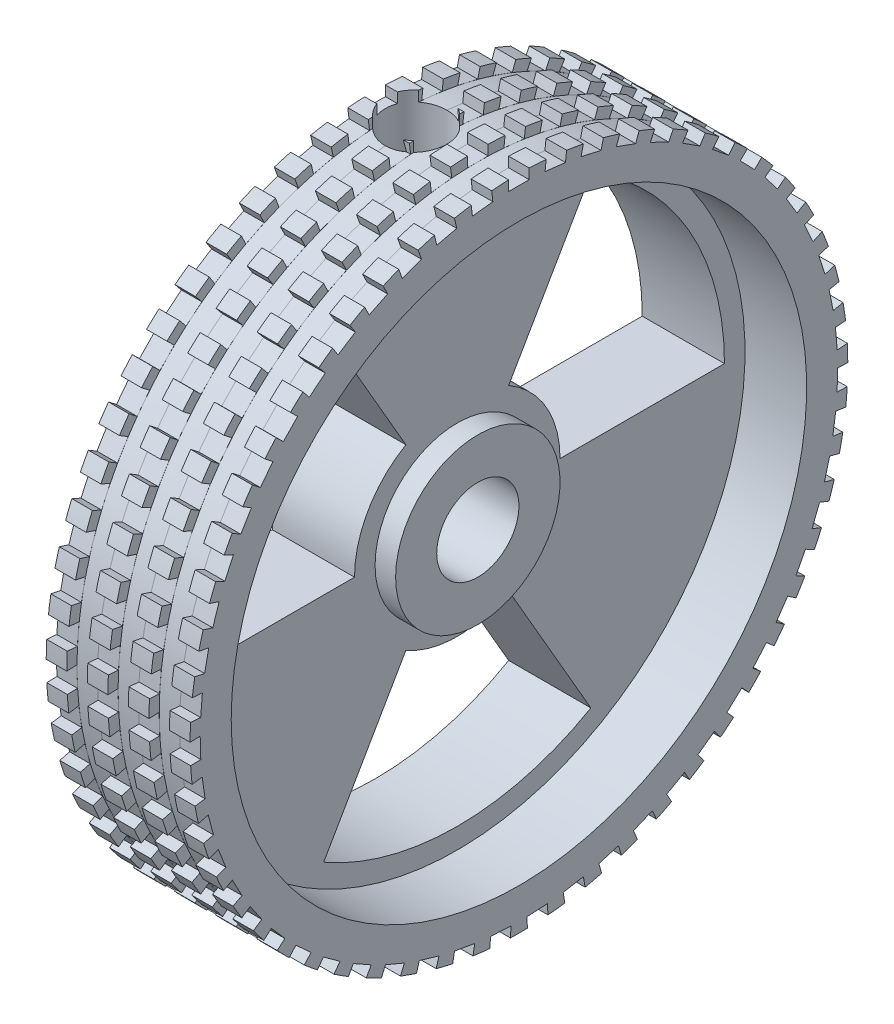
from build123d import *

# Parameters (mm, degrees)
SKETCH3_W          = 1
SKETCH3_H          = 0.5
SKETCH4_W          = 1
SKETCH4_H          = 0.5
CUT_EXTRUDE1_DEPTH = 10
LPATTERN1_COUNT    = 3
LPATTERN1_PITCH    = 2
CIRPATTERN1_COUNT  = 55
CUT_EXTRUDE3_DEPTH = 10
CIRPATTERN3_COUNT  = 3


with BuildPart() as part:
    # Sketch1 → Revolve1 (revolve)
    with BuildSketch(Plane(origin=(0, 0, 0), x_dir=(1, 0, 0), z_dir=(0, 1, 0))):
        Polygon((0, 2), (5, 2), (5, 4), (4, 4), (4, 14), (7, 14), (7, 16), (0, 16), align=None)
    revolve(axis=Axis((0, 0, 0), (1, 0, 0)))

    # Sketch2 → Cut-Revolve1 (revolve, cut)
    with BuildSketch(Plane.XY):
        Polygon((2, 16), (2, 0), (2.9, 0), (2.9, 11.5), (3.5, 11.5), (3.5, 16), align=None)
    revolve(axis=Axis((2, 0, 0), (0, 1, 0)), mode=Mode.SUBTRACT)

    # Sketch3 → Cut-Revolve5 (revolve, cut)
    with BuildSketch(Plane.XY):
        with Locations((5.5, 15.75)):
            Rectangle(SKETCH3_W, SKETCH3_H)
    cut_revolve5 = revolve(axis=Axis((0, 0, 0), (1, 0, 0)), mode=Mode.SUBTRACT)

    # Sketch4 → Cut-Extrude1 (cut)
    with BuildSketch(Plane.ZY):
        with Locations((0, 15.75)):
            Rectangle(SKETCH4_W, SKETCH4_H)
    cut_extrude1 = extrude(amount=-CUT_EXTRUDE1_DEPTH, mode=Mode.SUBTRACT)

    # LPattern1: Cut-Revolve5 ×3
    with Locations(*[(-i * LPATTERN1_PITCH, 0, 0) for i in range(1, LPATTERN1_COUNT)]):
        add(cut_revolve5, mode=Mode.SUBTRACT)

    # CirPattern1: Cut-Extrude1 ×55 about axis
    cirpattern1_axis = Axis((0, 0, 0), (1, 0, 0))
    for i in range(1, CIRPATTERN1_COUNT):
        add(cut_extrude1.rotate(cirpattern1_axis, i * 360 / CIRPATTERN1_COUNT), mode=Mode.SUBTRACT)

    # Sketch6 → Cut-Extrude3 (cut)
    with BuildSketch(Plane(origin=(4, 0, 0), x_dir=(0, 0, -1), z_dir=(1, 0, 0))):
        with BuildLine():
            Line((13, 0), (5, 0))
            ThreePointArc((5, 0), (4.330127019, 2.5), (2.5, 4.330127019))
            Line((2.5, 4.330127019), (6.5, 11.258330249))
            ThreePointArc((6.5, 11.258330249), (11.258330249, 6.5), (13, 0))
        make_face()
    cut_extrude3 = extrude(amount=-CUT_EXTRUDE3_DEPTH, mode=Mode.SUBTRACT)

    # CirPattern3: Cut-Extrude3 ×3 about axis
    cirpattern3_axis = Axis((0, 0, 0), (1, 0, 0))
    for i in range(1, CIRPATTERN3_COUNT):
        add(cut_extrude3.rotate(cirpattern3_axis, i * 360 / CIRPATTERN3_COUNT), mode=Mode.SUBTRACT)


solid = part.part
